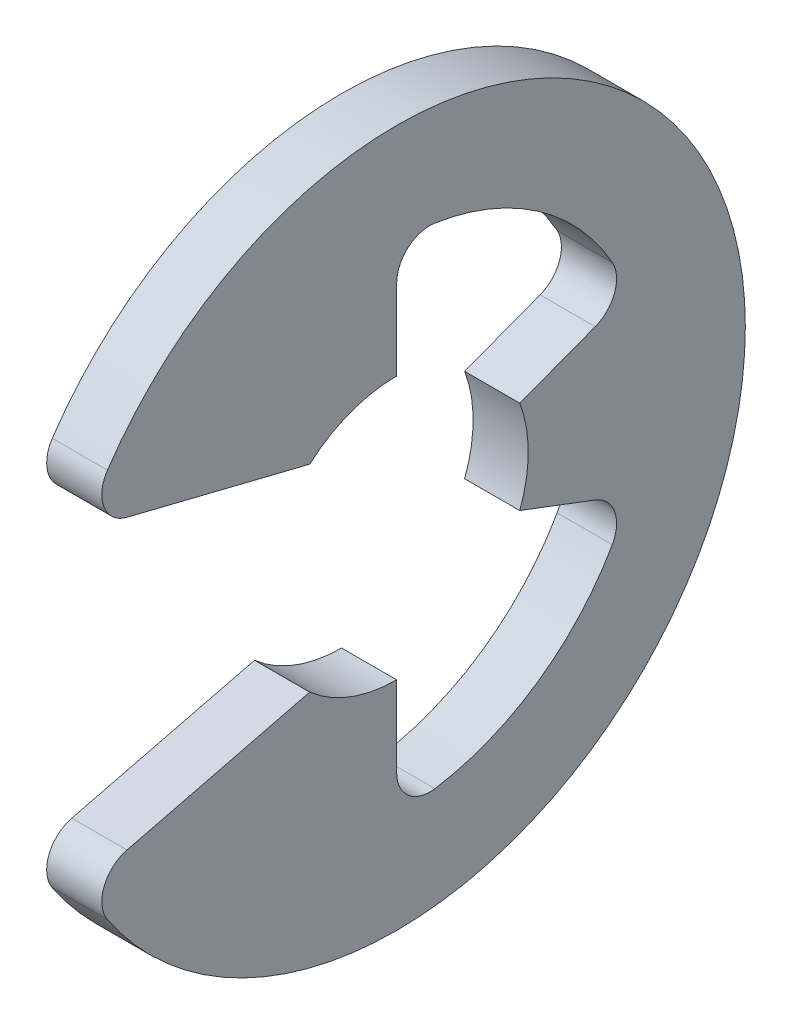
from build123d import *

# Parameters (mm, degrees)
RESSALTO_EXTRUS_O1_DEPTH = 0.7


with BuildPart() as part:
    # Esboço1 → Ressalto-extrusão1 (new body)
    with BuildSketch(Plane(origin=(0.35, 0, 0), x_dir=(0, 0, -1), z_dir=(1, 0, 0))):
        with BuildLine():
            Line((-1.104601172, -1.2525), (-3.423938468, -1.828316235))
            ThreePointArc((-3.423938468, -1.828316235), (-3.714684542, -2.08501745), (-3.671190238, -2.470422481))
            ThreePointArc((-3.671190238, -2.470422481), (4.425, 0), (-3.671190238, 2.470422481))
            ThreePointArc((-3.671190238, 2.470422481), (-3.714684542, 2.08501745), (-3.423938468, 1.828316235))
            Line((-3.423938468, 1.828316235), (-1.104601172, 1.2525))
            ThreePointArc((-1.104601172, 1.2525), (-0.590434162, 1.562141959), (0, 1.67))
            Line((0, 1.67), (0, 2.693254687))
            ThreePointArc((0, 2.693254687), (0.146851884, 3.012300306), (0.484714793, 3.108239019))
            ThreePointArc((0.484714793, 3.108239019), (1.788476887, 2.587942939), (2.736118813, 1.552337615))
            ThreePointArc((2.736118813, 1.552337615), (2.765828941, 1.202376345), (2.519309074, 0.952209327))
            Line((2.519309074, 0.952209327), (1.562141959, 0.590434162))
            ThreePointArc((1.562141959, 0.590434162), (1.67, 0), (1.562141959, -0.590434162))
            Line((1.562141959, -0.590434162), (2.519309074, -0.952209327))
            ThreePointArc((2.519309074, -0.952209327), (2.765828941, -1.202376345), (2.736118813, -1.552337615))
            ThreePointArc((2.736118813, -1.552337615), (1.788476887, -2.587942939), (0.484714793, -3.108239019))
            ThreePointArc((0.484714793, -3.108239019), (0.146851884, -3.012300306), (0, -2.693254687))
            Line((0, -2.693254687), (0, -1.67))
            ThreePointArc((0, -1.67), (-0.590434162, -1.562141959), (-1.104601172, -1.2525))
        make_face()
    extrude(amount=-RESSALTO_EXTRUS_O1_DEPTH)


solid = part.part
